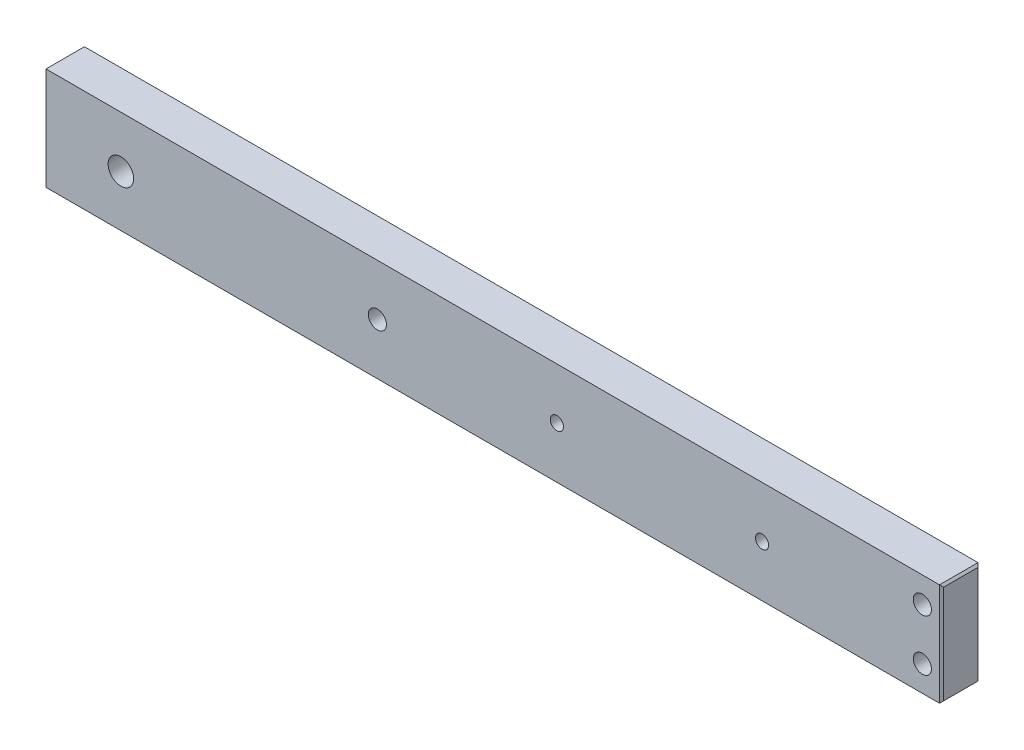
from build123d import *

# Parameters (mm, degrees)
SKETCH1_W                 = 222.25
SKETCH1_H                 = 25.4
BOSS_EXTRUDE1_DEPTH       = 9.525
F_8_CLEARANCE_HOLE1_D     = 4.4958
F_8_CLEARANCE_HOLE1_DEPTH = 25.4
F_8_CLEARANCE_HOLE1_TIP   = 1.350674586
SKETCH5_R                 = 3.1623
CUT_EXTRUDE1_DEPTH        = 9.525
F_8_CLEARANCE_HOLE2_D     = 4.4958
F_8_CLEARANCE_HOLE2_DEPTH = 19.05
F_8_CLEARANCE_HOLE2_TIP   = 1.350674586
CHAMFER1_SIZE             = 0.508
F_4_CLEARANCE_HOLE1_D     = 3.2639


with BuildPart() as part:
    # Sketch1 → Boss-Extrude1 (new body)
    with BuildSketch(Plane.XY):
        with Locations((-111.125, 12.7)):
            Rectangle(SKETCH1_W, SKETCH1_H)
    extrude(amount=BOSS_EXTRUDE1_DEPTH)

    # #8 Clearance Hole1
    with Locations(Plane.XY.offset(9.525)):
        with Locations((-4.7625, 6.35), (-4.7625, 19.05)):
            Hole(F_8_CLEARANCE_HOLE1_D / 2, depth=F_8_CLEARANCE_HOLE1_DEPTH)
            with Locations((0, 0, -(F_8_CLEARANCE_HOLE1_DEPTH + F_8_CLEARANCE_HOLE1_TIP / 2))):  # 118° drill point
                Cone(0, F_8_CLEARANCE_HOLE1_D / 2, F_8_CLEARANCE_HOLE1_TIP, mode=Mode.SUBTRACT)

    # Sketch5 → Cut-Extrude1 (cut)
    with BuildSketch(Plane.XY.offset(9.525)):
        with Locations((-203.2, 12.7)):
            Circle(SKETCH5_R)
    extrude(amount=-CUT_EXTRUDE1_DEPTH, mode=Mode.SUBTRACT)

    # #8 Clearance Hole2
    with Locations(Plane.XY.offset(9.525)):
        with Locations((-139.7, 12.7)):
            Hole(F_8_CLEARANCE_HOLE2_D / 2, depth=F_8_CLEARANCE_HOLE2_DEPTH)
            with Locations((0, 0, -(F_8_CLEARANCE_HOLE2_DEPTH + F_8_CLEARANCE_HOLE2_TIP / 2))):  # 118° drill point
                Cone(0, F_8_CLEARANCE_HOLE2_D / 2, F_8_CLEARANCE_HOLE2_TIP, mode=Mode.SUBTRACT)

    # Chamfer1
    chamfer1_edges = [part.edges().sort_by_distance(p)[0] for p in [
        (-222.25, 12.7, 9.525),
        (0, 12.7, 9.525),
        (-222.25, 12.7, 0),
        (0, 12.7, 0),
        (0, 0, 4.7625),
        (-222.25, 0, 4.7625),
        (-222.25, 25.4, 4.7625),
        (0, 25.4, 4.7625),
    ]]
    chamfer(chamfer1_edges, length=CHAMFER1_SIZE)

    # #4 Clearance Hole1 (through all)
    with Locations(Plane(origin=(0, 0, 0), x_dir=(-1, 0, 0), z_dir=(0, 0, -1))):
        with Locations((95.25, 12.7), (44.45, 12.7)):
            Hole(F_4_CLEARANCE_HOLE1_D / 2)


solid = part.part
